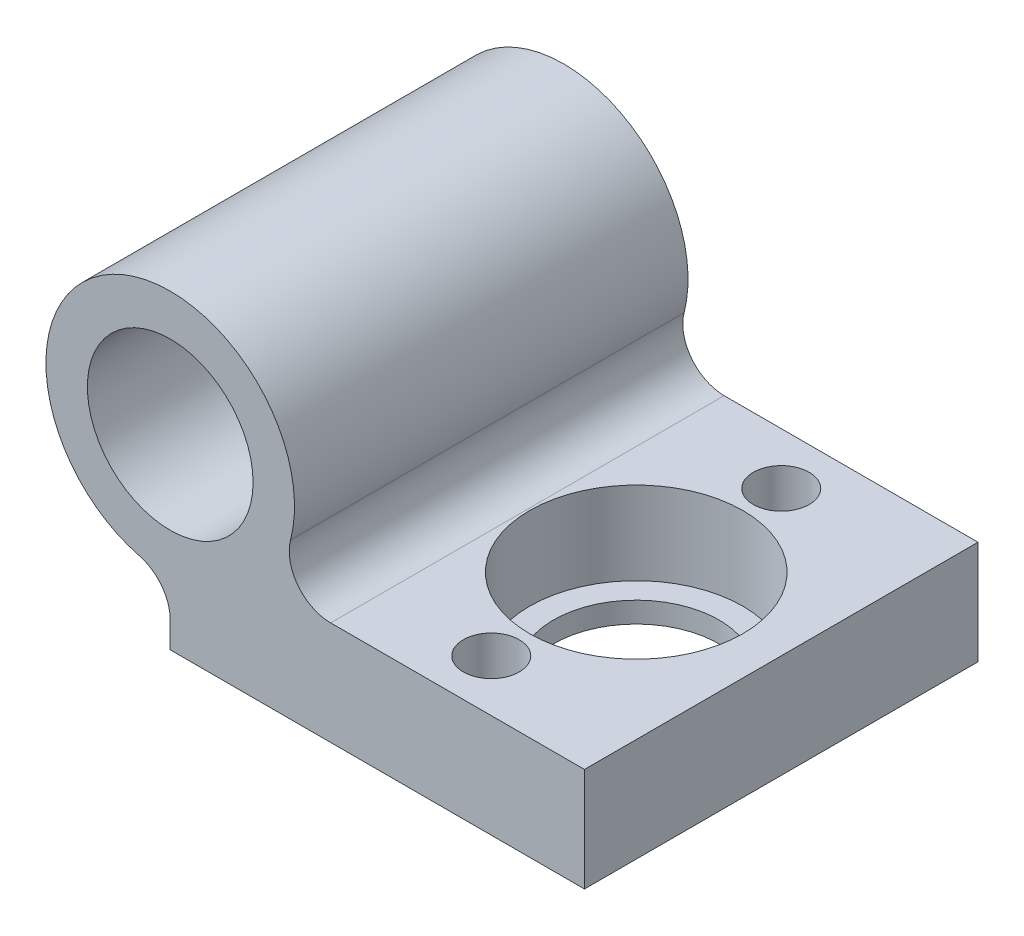
from build123d import *

# Parameters (mm, degrees)
SKETCH1_R                  = 6
SKETCH1_R_2                = 4
MAIN_DEPTH                 = 9.5
SKETCH2_W                  = 20
SKETCH2_H                  = 19
SKETCH2_R                  = 4
SKETCH2_R_2                = 1.35
BALLSUPPORTEXTRUSION_DEPTH = 5
SKETCH3_R                  = 5.15
BALLSUPPORTHOLE_DEPTH      = 4
FILLET2_R                  = 2


with BuildPart() as part:
    # Sketch1 → Main (new body, symmetric)
    with BuildSketch(Plane.XY):
        Circle(SKETCH1_R)
        Circle(SKETCH1_R_2, mode=Mode.SUBTRACT)
    extrude(amount=MAIN_DEPTH, both=True)

    # Sketch2 → BallSupportExtrusion (add)
    with BuildSketch(Plane(origin=(0, -9, 0), x_dir=(1, 0, 0), z_dir=(0, 1, 0))):
        with Locations((10, 0)):
            Rectangle(SKETCH2_W, SKETCH2_H)
        with Locations((13, 0)):
            Circle(SKETCH2_R, mode=Mode.SUBTRACT)
        with Locations((13, 7)):
            Circle(SKETCH2_R_2, mode=Mode.SUBTRACT)
        with Locations((13, -7)):
            Circle(SKETCH2_R_2, mode=Mode.SUBTRACT)
    extrude(amount=BALLSUPPORTEXTRUSION_DEPTH)

    # Sketch3 → BallSupportHole (cut)
    with BuildSketch(Plane(origin=(0, -4, 0), x_dir=(1, 0, 0), z_dir=(0, 1, 0))):
        with Locations((13, 0)):
            Circle(SKETCH3_R)
    extrude(amount=-BALLSUPPORTHOLE_DEPTH, mode=Mode.SUBTRACT)

    # Fillet2
    fillet2_edges = [part.edges().sort_by_distance(p)[0] for p in [
        (0, -6, 0),
        (4.472135955, -4, 0),
    ]]
    fillet(fillet2_edges, radius=FILLET2_R)


solid = part.part
